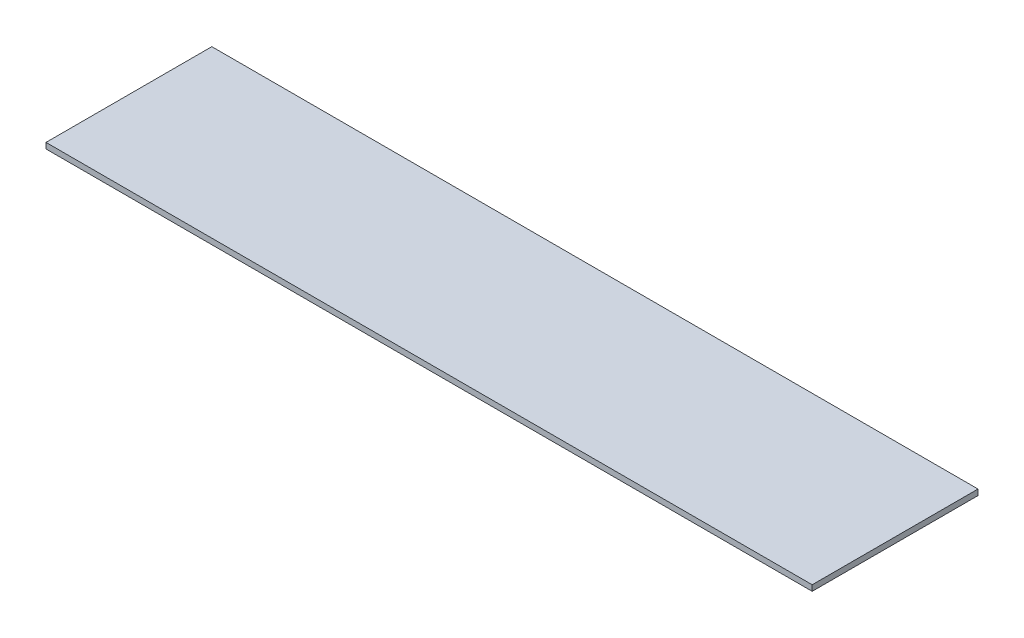
from build123d import *

# Parameters (mm, degrees)
SZKIC1_W                    = 1340
SZKIC1_H                    = 10
DODANIE_WYCI_GNI_CIE1_DEPTH = 290


with BuildPart() as part:
    # Szkic1 → Dodanie-wyciągnięcie1 (new body)
    with BuildSketch(Plane.XY):
        with Locations((-633.895875804, 1.642857143)):
            Rectangle(SZKIC1_W, SZKIC1_H)
    extrude(amount=DODANIE_WYCI_GNI_CIE1_DEPTH)


solid = part.part
